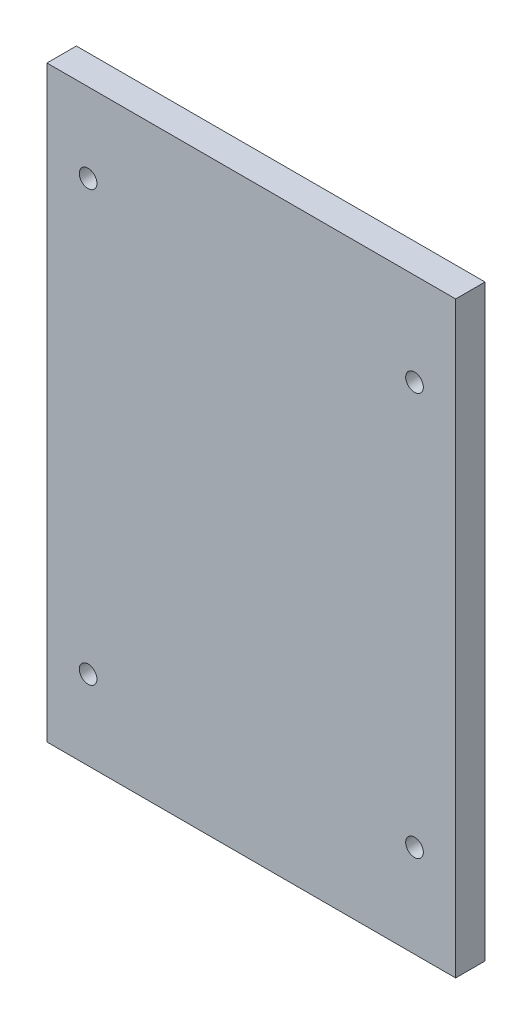
from build123d import *

# Parameters (mm, degrees)
SKETCH_1_W      = 69.5
SKETCH_1_H      = 100
SKETCH_1_R      = 1.5
EXTRUDE_1_DEPTH = 5


with BuildPart() as part:
    # Эскиз1 → Бобышка-Вытянуть1 (new body)
    with BuildSketch(Plane.XY.offset(81)):
        with Locations((-32.25, 45)):
            Rectangle(SKETCH_1_W, SKETCH_1_H)
        with Locations((-60, 8.5)):
            Circle(SKETCH_1_R, mode=Mode.SUBTRACT)
        with Locations((-60, 81.5)):
            Circle(SKETCH_1_R, mode=Mode.SUBTRACT)
        with Locations((-4.5, 79.25)):
            Circle(SKETCH_1_R, mode=Mode.SUBTRACT)
        with Locations((-4.5, 10.75)):
            Circle(SKETCH_1_R, mode=Mode.SUBTRACT)
    extrude(amount=-EXTRUDE_1_DEPTH)


solid = part.part
